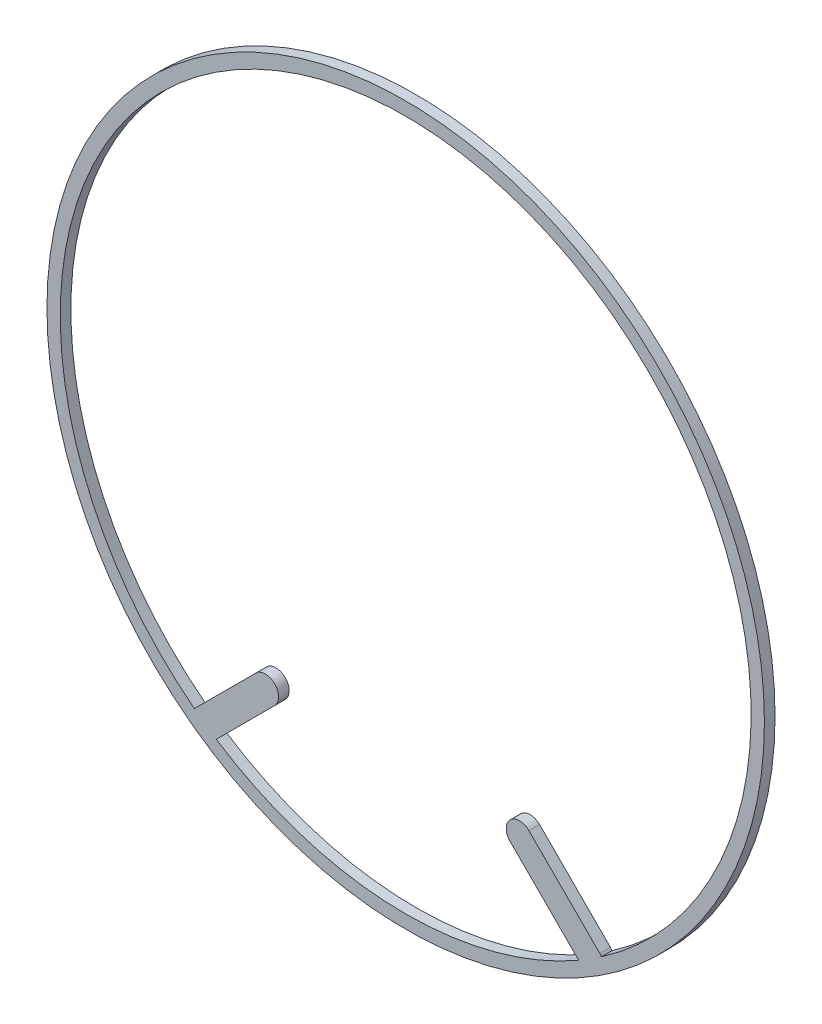
from build123d import *

# Parameters (mm, degrees)
SKETCH1_R           = 85.725
BOSS_EXTRUDE2_DEPTH = 2.54


with BuildPart() as part:
    # Sketch1 → Boss-Extrude2 (new body)
    with BuildSketch(Plane.XY):
        Circle(SKETCH1_R)
        with BuildLine():
            ThreePointArc((-50.476604824, -65.319329952), (2.284509609, 82.518382896), (46.785345693, -68.012013118))
            ThreePointArc((46.785345693, -68.012013118), (46.595439838, -67.75364435), (46.380442263, -67.515747951))
            Line((46.380442263, -67.515747951), (29.451630282, -50.58693597))
            ThreePointArc((29.451630282, -50.58693597), (24.961502222, -50.58693597), (24.961502222, -55.07706403))
            Line((24.961502222, -55.07706403), (41.33826935, -71.453831158))
            ThreePointArc((41.33826935, -71.453831158), (-2.304078902, -82.517838801), (-45.26104742, -69.035788447))
            Line((-45.26104742, -69.035788447), (-31.302323003, -55.07706403))
            ThreePointArc((-31.302323003, -55.07706403), (-31.302323003, -50.58693597), (-35.792451064, -50.58693597))
            Line((-35.792451064, -50.58693597), (-50.172516759, -64.967001665))
            ThreePointArc((-50.172516759, -64.967001665), (-50.331025251, -65.137586452), (-50.476604824, -65.319329952))
        make_face(mode=Mode.SUBTRACT)
    extrude(amount=BOSS_EXTRUDE2_DEPTH)


solid = part.part
